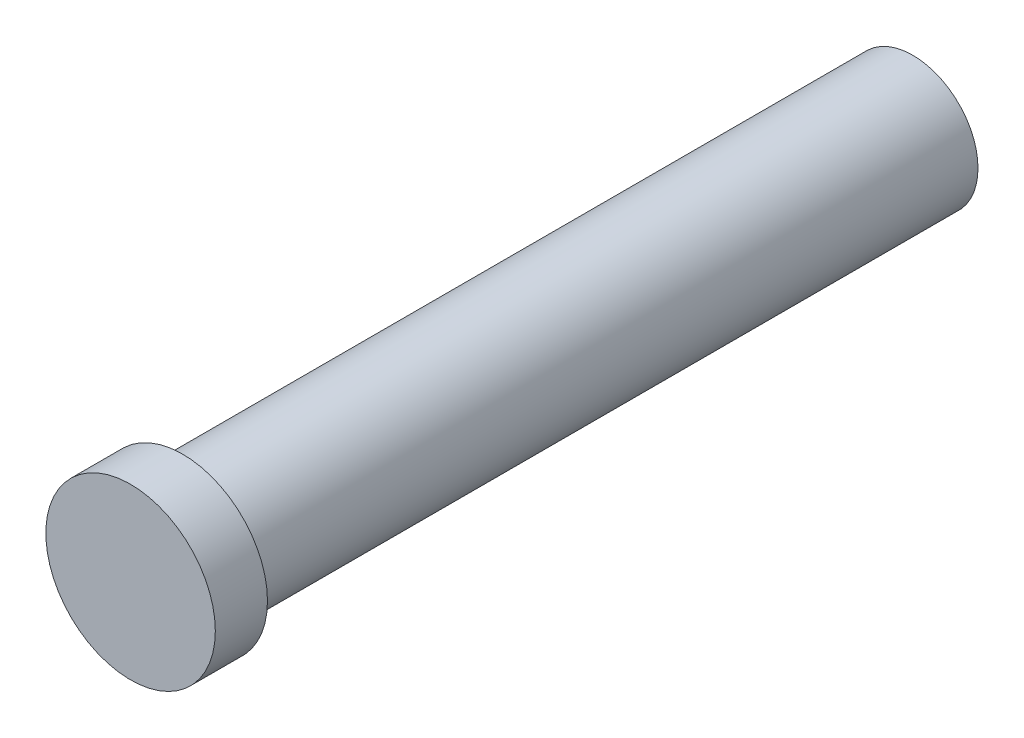
from build123d import *

# Parameters (mm, degrees)
SKETCH_1_R             = 5
EXTRUDE_1_DEPTH        = 56
SKETCH_2_R             = 6.5
EXTRUDE_2_DEPTH        = 4
HOLE_WIZARD_M6_1_D     = 5
HOLE_WIZARD_M6_1_DEPTH = 15
HOLE_WIZARD_M6_1_TIP   = 1.502151548


with BuildPart() as part:
    # 草图1 → 凸台-拉伸1 (new body)
    with BuildSketch(Plane.XY):
        Circle(SKETCH_1_R)
    extrude(amount=EXTRUDE_1_DEPTH)

    # 草图2 → 凸台-拉伸2 (add)
    with BuildSketch(Plane.XY.offset(56)):
        Circle(SKETCH_2_R)
    extrude(amount=EXTRUDE_2_DEPTH)

    # M6 螺纹孔1
    with Locations(Plane(origin=(0, 0, 0), x_dir=(-1, 0, 0), z_dir=(0, 0, -1))):
        with Locations((0, 0)):
            Hole(HOLE_WIZARD_M6_1_D / 2, depth=HOLE_WIZARD_M6_1_DEPTH)
            with Locations((0, 0, -(HOLE_WIZARD_M6_1_DEPTH + HOLE_WIZARD_M6_1_TIP / 2))):  # 118° drill point
                Cone(0, HOLE_WIZARD_M6_1_D / 2, HOLE_WIZARD_M6_1_TIP, mode=Mode.SUBTRACT)


solid = part.part
